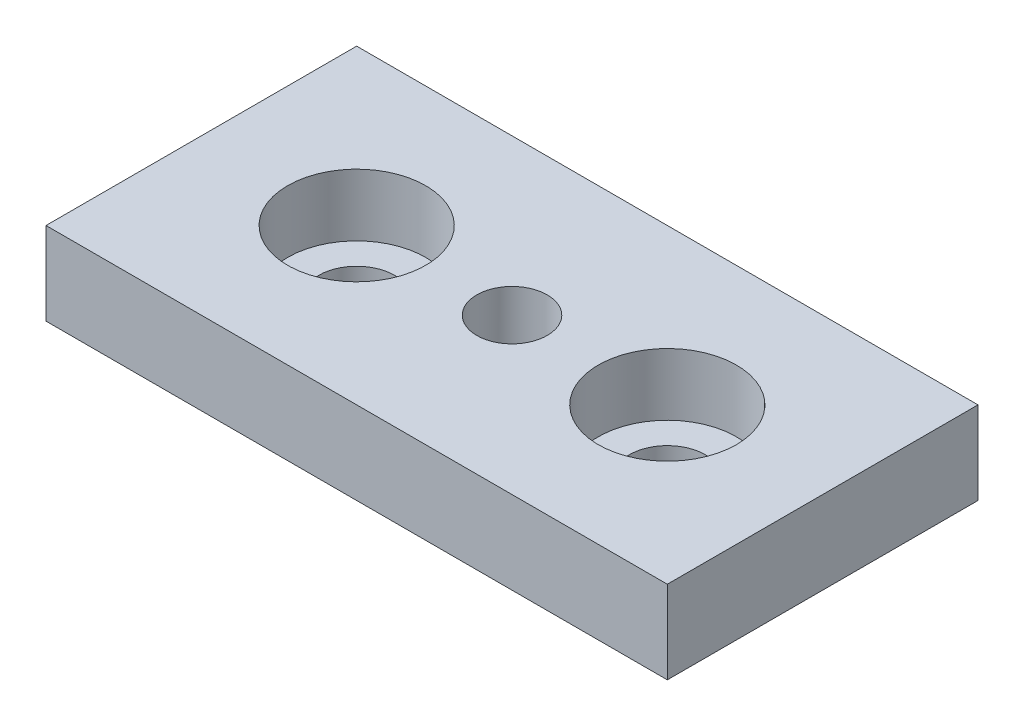
from build123d import *

# Parameters (mm, degrees)
SKETCH_1_W             = 90
SKETCH_1_H             = 45
EXTRUDE_1_DEPTH        = 12
HOLE_WIZARD_M121_D     = 10.2
HOLE_WIZARD_M121_DEPTH = 12


with BuildPart() as part:
    # Эскиз1 → Бобышка-Вытянуть1 (new body)
    with BuildSketch(Plane(origin=(0, 0, 0), x_dir=(1, 0, 0), z_dir=(0, 1, 0))):
        Rectangle(SKETCH_1_W, SKETCH_1_H)
    extrude(amount=EXTRUDE_1_DEPTH)

    # Эскиз2 → Вырез-Повернуть1 (revolve, cut)
    with BuildSketch(Plane.XY):
        Polygon((-32.5, 12), (-32.5, 3), (-28, 3), (-28, 0), (-22.5, 0), (-22.5, 12), align=None)
    cut_revolve_1 = revolve(axis=Axis((-22.5, 12, 0), (0, -1, 0)), mode=Mode.SUBTRACT)

    # Зеркальное отражение1: Вырез-Повернуть1 across plane
    add(cut_revolve_1.mirror(Plane(origin=(0, 0, 0), x_dir=(0, 0, 1), z_dir=(1, 0, 0))), mode=Mode.SUBTRACT)

    # Отверстие обработанное метчиком M121
    with Locations(Plane(origin=(0, 12, 0), x_dir=(1, 0, 0), z_dir=(0, 1, 0))):
        with Locations((0, 0)):
            Hole(HOLE_WIZARD_M121_D / 2, depth=HOLE_WIZARD_M121_DEPTH)


solid = part.part
